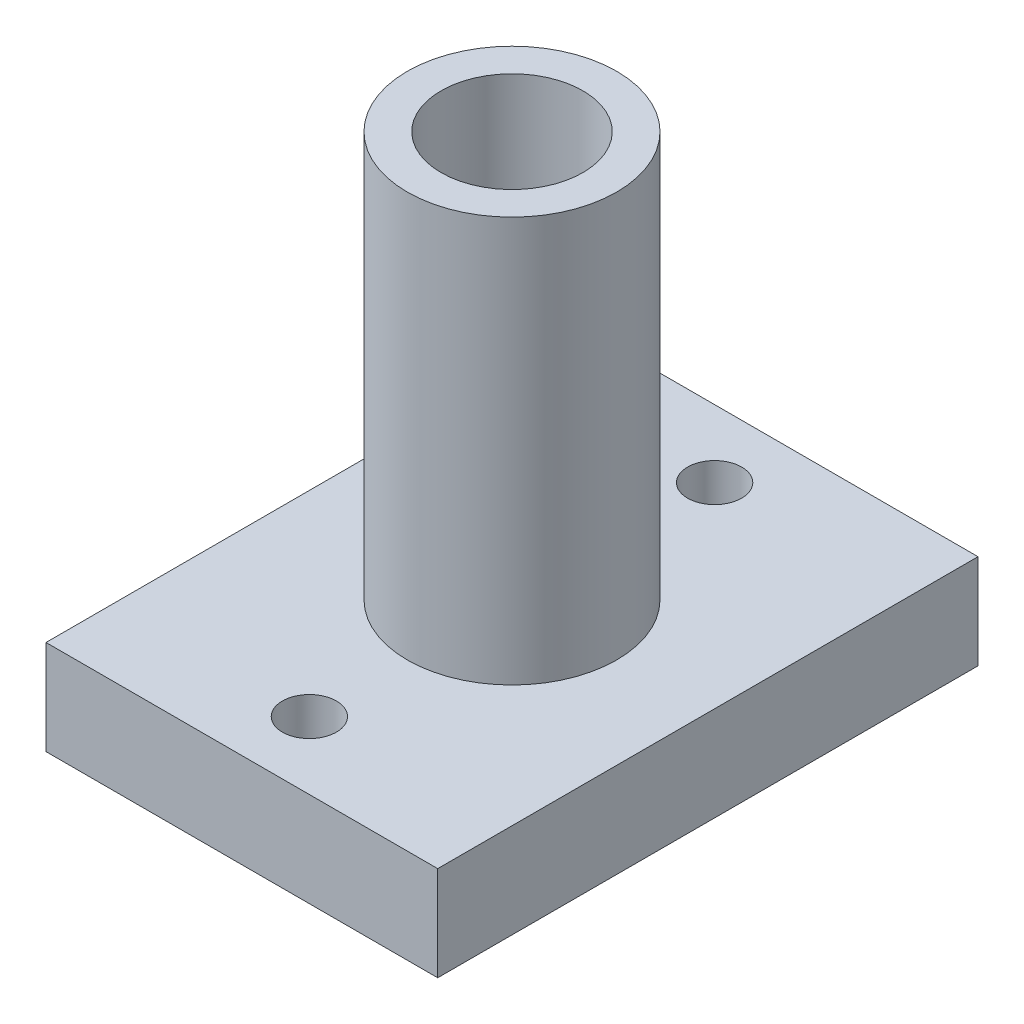
from build123d import *

# Parameters (mm, degrees)
SKETCH1_W           = 29
SKETCH1_H           = 7
BOSS_EXTRUDE1_DEPTH = 20
SKETCH2_R           = 2
CUT_EXTRUDE1_DEPTH  = 8
SKETCH3_R           = 7.75
SKETCH3_R_2         = 5.25
EXTRUDE_THIN1_DEPTH = 30


with BuildPart() as part:
    # Sketch1 → Boss-Extrude1 (new body, symmetric)
    with BuildSketch(Plane.XY):
        Rectangle(SKETCH1_W, SKETCH1_H)
    extrude(amount=BOSS_EXTRUDE1_DEPTH, both=True)

    # Sketch2 → Cut-Extrude1 (cut, through all)
    with BuildSketch(Plane(origin=(0, 3.5, 0), x_dir=(1, 0, 0), z_dir=(0, 1, 0))):
        with Locations((0, 15)):
            Circle(SKETCH2_R)
        with Locations((0, -15)):
            Circle(SKETCH2_R)
    extrude(amount=-CUT_EXTRUDE1_DEPTH, mode=Mode.SUBTRACT)

    # Sketch3 → Extrude-Thin1 (add)
    with BuildSketch(Plane(origin=(0, 3.5, 0), x_dir=(1, 0, 0), z_dir=(0, 1, 0))):
        Circle(SKETCH3_R)
        Circle(SKETCH3_R_2, mode=Mode.SUBTRACT)
    extrude(amount=EXTRUDE_THIN1_DEPTH)


solid = part.part
